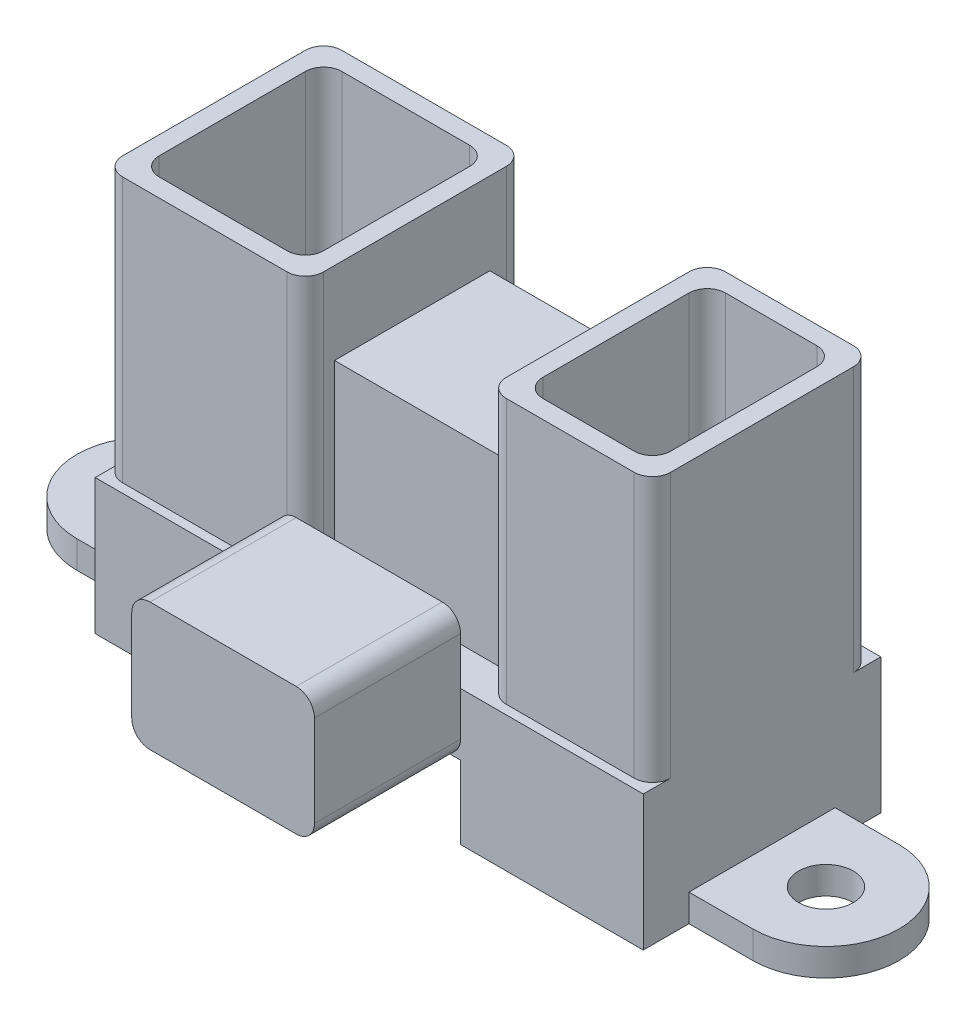
from build123d import *

# Parameters (mm, degrees)
SKETCH1_W           = 30
SKETCH1_H           = 13
BOSS_EXTRUDE1_DEPTH = 7.4
BOSS_EXTRUDE2_DEPTH = 14.5
SKETCH3_W           = 10
SKETCH3_H           = 8.5
BOSS_EXTRUDE3_DEPTH = 10
SKETCH5_R           = 1.5
BOSS_EXTRUDE4_DEPTH = 1.5
CUT_EXTRUDE2_DEPTH  = 4
SKETCH7_W           = 10
SKETCH7_H           = 7
BOSS_EXTRUDE5_DEPTH = 8
FILLET1_R           = 1


with BuildPart() as part:
    # Sketch1 → Boss-Extrude1 (new body)
    with BuildSketch(Plane(origin=(0, 0, 0), x_dir=(1, 0, 0), z_dir=(0, 1, 0))):
        Rectangle(SKETCH1_W, SKETCH1_H)
    extrude(amount=BOSS_EXTRUDE1_DEPTH)

    # Sketch2 → Boss-Extrude2 (add)
    with BuildSketch(Plane(origin=(0, 7.4, 0), x_dir=(1, 0, 0), z_dir=(0, 1, 0))):
        with BuildLine():
            Line((-14, 6), (-5, 6))
            ThreePointArc((-5, 6), (-4.292893219, 5.707106781), (-4, 5))
            Line((-4, 5), (-4, -5))
            ThreePointArc((-4, -5), (-4.292893219, -5.707106781), (-5, -6))
            Line((-5, -6), (-14, -6))
            ThreePointArc((-14, -6), (-14.707106781, -5.707106781), (-15, -5))
            Line((-15, -5), (-15, 5))
            ThreePointArc((-15, 5), (-14.707106781, 5.707106781), (-14, 6))
        make_face()
        with BuildLine():
            Line((-13, 5), (-6, 5))
            ThreePointArc((-6, 5), (-5.292893219, 4.707106781), (-5, 4))
            Line((-5, 4), (-5, -4))
            ThreePointArc((-5, -4), (-5.292893219, -4.707106781), (-6, -5))
            Line((-6, -5), (-13, -5))
            ThreePointArc((-13, -5), (-13.707106781, -4.707106781), (-14, -4))
            Line((-14, -4), (-14, 4))
            ThreePointArc((-14, 4), (-13.707106781, 4.707106781), (-13, 5))
        make_face(mode=Mode.SUBTRACT)
        with BuildLine():
            Line((14, 6), (7, 6))
            ThreePointArc((7, 6), (6.292893219, 5.707106781), (6, 5))
            Line((6, 5), (6, -5))
            ThreePointArc((6, -5), (6.292893219, -5.707106781), (7, -6))
            Line((7, -6), (14, -6))
            ThreePointArc((14, -6), (14.707106781, -5.707106781), (15, -5))
            Line((15, -5), (15, 5))
            ThreePointArc((15, 5), (14.707106781, 5.707106781), (14, 6))
        make_face()
        with BuildLine():
            Line((8, -5), (13, -5))
            ThreePointArc((13, -5), (13.707106781, -4.707106781), (14, -4))
            Line((14, -4), (14, 4))
            ThreePointArc((14, 4), (13.707106781, 4.707106781), (13, 5))
            Line((13, 5), (8, 5))
            ThreePointArc((8, 5), (7.292893219, 4.707106781), (7, 4))
            Line((7, 4), (7, -4))
            ThreePointArc((7, -4), (7.292893219, -4.707106781), (8, -5))
        make_face(mode=Mode.SUBTRACT)
    extrude(amount=BOSS_EXTRUDE2_DEPTH)

    # Sketch3 → Boss-Extrude3 (add)
    with BuildSketch(Plane(origin=(0, 7.4, 0), x_dir=(1, 0, 0), z_dir=(0, 1, 0))):
        with Locations((1, -0.15)):
            Rectangle(SKETCH3_W, SKETCH3_H)
    extrude(amount=BOSS_EXTRUDE3_DEPTH)

    # Sketch5 → Boss-Extrude4 (add)
    with BuildSketch(Plane(origin=(0, 0, 0), x_dir=(1, 0, 0), z_dir=(0, 1, 0))):
        with BuildLine():
            Line((-18.5, 4), (18.5, 4))
            ThreePointArc((18.5, 4), (22.5, 0), (18.5, -4))
            Line((18.5, -4), (-18.5, -4))
            ThreePointArc((-18.5, -4), (-22.5, 0), (-18.5, 4))
        make_face()
        with Locations((-18.5, 0)):
            Circle(SKETCH5_R, mode=Mode.SUBTRACT)
        with Locations((18.5, 0)):
            Circle(SKETCH5_R, mode=Mode.SUBTRACT)
    extrude(amount=BOSS_EXTRUDE4_DEPTH)

    # Sketch6 → Cut-Extrude2 (cut)
    with BuildSketch(Plane.XZ):
        Polygon((-14, 5.5), (-5, 5.5), (-5, 6.5), (5, 6.5), (5, 5.5), (14, 5.5), (14, -5.5), (-14, -5.5), align=None)
    extrude(amount=-CUT_EXTRUDE2_DEPTH, mode=Mode.SUBTRACT)

    # Sketch7 → Boss-Extrude5 (add)
    with BuildSketch(Plane.XY.offset(6.5)):
        with Locations((0, 7.5)):
            Rectangle(SKETCH7_W, SKETCH7_H)
    extrude(amount=BOSS_EXTRUDE5_DEPTH)

    # Fillet1
    fillet1_edges = [part.edges().sort_by_distance(p)[0] for p in [
        (-5, 11, 10.5),
        (-5, 4, 10.5),
        (5, 4, 10.5),
        (5, 11, 10.5),
    ]]
    fillet(fillet1_edges, radius=FILLET1_R)


solid = part.part
